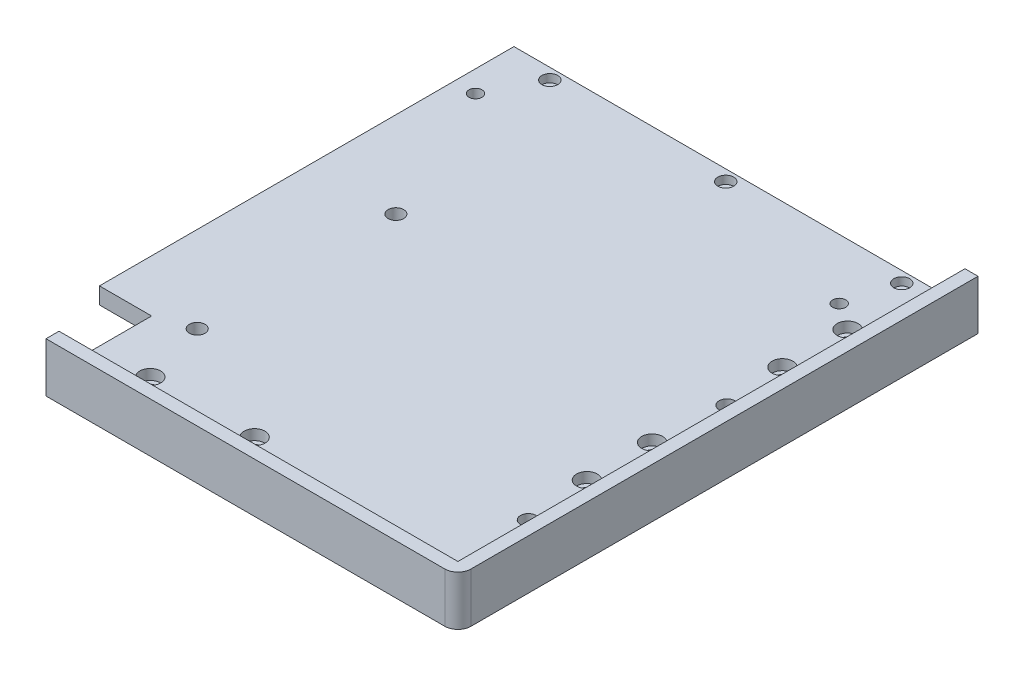
from build123d import *

# Parameters (mm, degrees)
SKETCH1_W                      = 158
SKETCH1_H                      = 199.5
BOSS_EXTRUDE1_DEPTH            = 6.35
BOSS_EXTRUDE2_DEPTH            = 12.7
CBORE_FOR_M4_SHCS1_D           = 4.5
CBORE_FOR_M4_SHCS1_DEPTH       = 6.35
CBORE_FOR_M4_SHCS1_CBORE_D     = 8
CBORE_FOR_M4_SHCS1_CBORE_DEPTH = 4
FILLET4_R                      = 5
SKETCH17_W                     = 20
SKETCH17_H                     = 159
BOSS_EXTRUDE3_DEPTH            = 6.35
SKETCH18_R                     = 3
ENCLOSURE_DEPTH                = 7.35
SKETCH19_R                     = 2.5
CUT_EXTRUDE4_DEPTH             = 7.35
SKETCH20_R                     = 3.05
CUT_EXTRUDE5_DEPTH             = 3.1


with BuildPart() as part:
    # Sketch1 → Boss-Extrude1 (new body)
    with BuildSketch(Plane(origin=(0, 0, 0), x_dir=(1, 0, 0), z_dir=(0, 1, 0))):
        with Locations((79, -99.75)):
            Rectangle(SKETCH1_W, SKETCH1_H)
    extrude(amount=BOSS_EXTRUDE1_DEPTH)

    # Sketch3 → Boss-Extrude2 (add)
    with BuildSketch(Plane(origin=(0, 6.35, 0), x_dir=(1, 0, 0), z_dir=(0, 1, 0))):
        Polygon((158, -199.5), (158, 0), (153, 0), (153, -194.5), (0, -194.5), (0, -199.5), align=None)
    extrude(amount=BOSS_EXTRUDE2_DEPTH)

    # CBORE for M4 SHCS1
    with Locations(Plane(origin=(0, 6.35, 0), x_dir=(1, 0, 0), z_dir=(0, 1, 0))):
        with Locations((138, -55), (20, -179.5), (60, -179.5), (138, -130), (138, -105), (138, -30)):
            CounterBoreHole(CBORE_FOR_M4_SHCS1_D / 2, CBORE_FOR_M4_SHCS1_CBORE_D / 2, CBORE_FOR_M4_SHCS1_CBORE_DEPTH, depth=CBORE_FOR_M4_SHCS1_DEPTH)

    # Fillet4
    fillet4_edges = [part.edges().sort_by_distance(p)[0] for p in [
        (158, 9.525, 199.5),
    ]]
    fillet(fillet4_edges, radius=FILLET4_R)

    # Sketch17 → Boss-Extrude3 (add)
    with BuildSketch(Plane(origin=(0, 6.35, 0), x_dir=(1, 0, 0), z_dir=(0, 1, 0))):
        with Locations((-10, -79.5)):
            Rectangle(SKETCH17_W, SKETCH17_H)
    extrude(amount=-BOSS_EXTRUDE3_DEPTH)

    # Sketch18 → Enclosure (cut, through all)
    with BuildSketch(Plane(origin=(0, 6.35, 0), x_dir=(1, 0, 0), z_dir=(0, 1, 0))):
        with Locations((13, -154.5)):
            Circle(SKETCH18_R)
        with Locations((13, -78.3)):
            Circle(SKETCH18_R)
        with Locations((140, -78.3)):
            Circle(SKETCH18_R)
        with Locations((140, -154.5)):
            Circle(SKETCH18_R)
    extrude(amount=-ENCLOSURE_DEPTH, mode=Mode.SUBTRACT)

    # Sketch19 → Cut-Extrude4 (cut, through all)
    with BuildSketch(Plane(origin=(0, 6.35, 0), x_dir=(1, 0, 0), z_dir=(0, 1, 0))):
        with Locations((-11.75, -23)):
            Circle(SKETCH19_R)
        with Locations((127.75, -23)):
            Circle(SKETCH19_R)
    extrude(amount=-CUT_EXTRUDE4_DEPTH, mode=Mode.SUBTRACT)

    # Sketch20 → Cut-Extrude5 (cut)
    with BuildSketch(Plane(origin=(0, 6.35, 0), x_dir=(1, 0, 0), z_dir=(0, 1, 0))):
        with Locations((133, -4.25)):
            Circle(SKETCH20_R)
        with Locations((65.5, -4.25)):
            Circle(SKETCH20_R)
        with Locations((-2, -4.25)):
            Circle(SKETCH20_R)
    extrude(amount=-CUT_EXTRUDE5_DEPTH, mode=Mode.SUBTRACT)


solid = part.part
